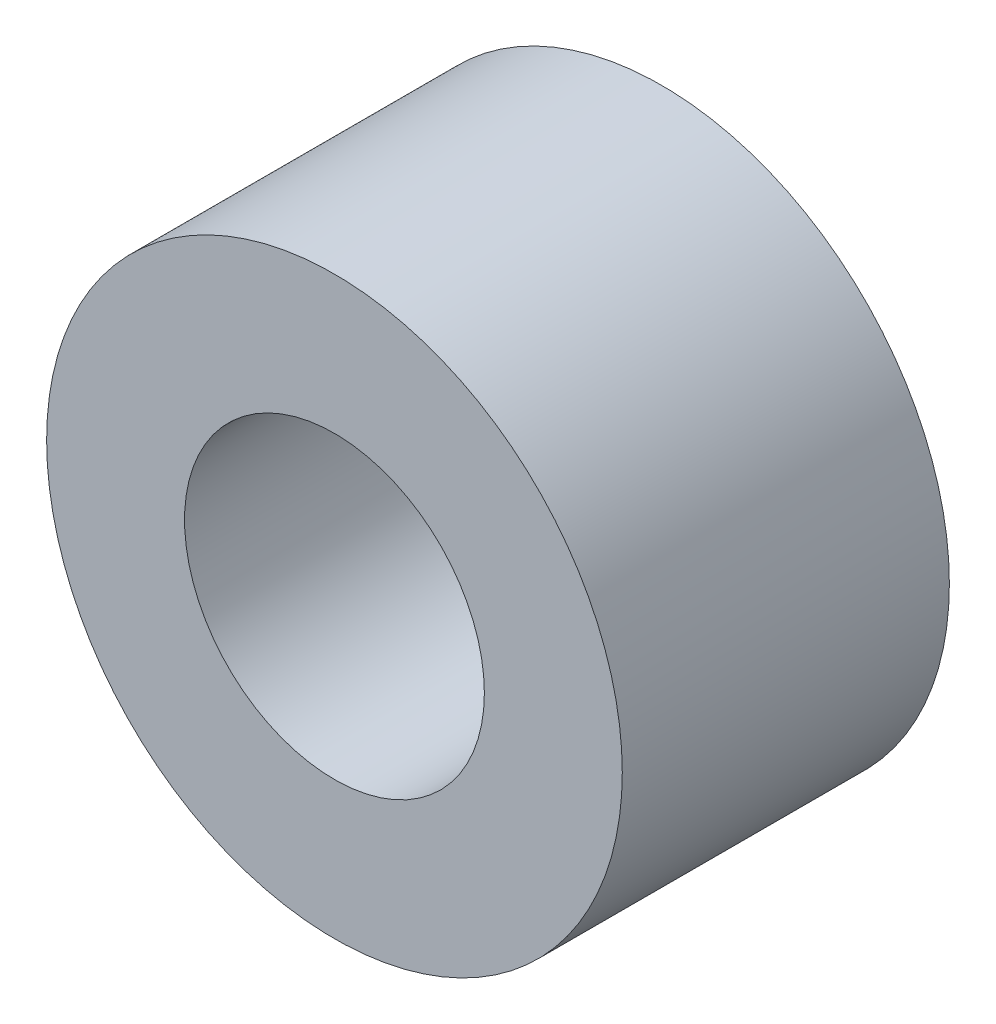
from build123d import *

# Parameters (mm, degrees)
SKETCH1_R           = 8.382
SKETCH1_R_2         = 4.365625
BOSS_EXTRUDE1_DEPTH = 9.525


with BuildPart() as part:
    # Sketch1 → Boss-Extrude1 (new body)
    with BuildSketch(Plane.XY):
        Circle(SKETCH1_R)
        Circle(SKETCH1_R_2, mode=Mode.SUBTRACT)
    extrude(amount=BOSS_EXTRUDE1_DEPTH)


solid = part.part
